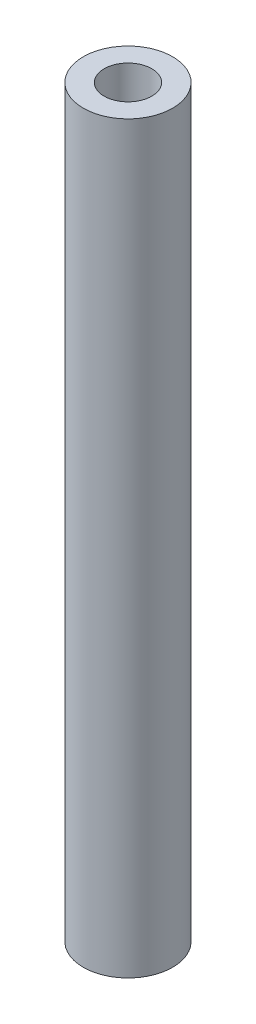
from build123d import *

# Parameters (mm, degrees)
SKETCH1_R           = 3
SKETCH1_R_2         = 1.6
BOSS_EXTRUDE1_DEPTH = 50


with BuildPart() as part:
    # Sketch1 → Boss-Extrude1 (new body)
    with BuildSketch(Plane(origin=(0, 0, 0), x_dir=(1, 0, 0), z_dir=(0, 1, 0))):
        Circle(SKETCH1_R)
        Circle(SKETCH1_R_2, mode=Mode.SUBTRACT)
    extrude(amount=BOSS_EXTRUDE1_DEPTH)


solid = part.part
